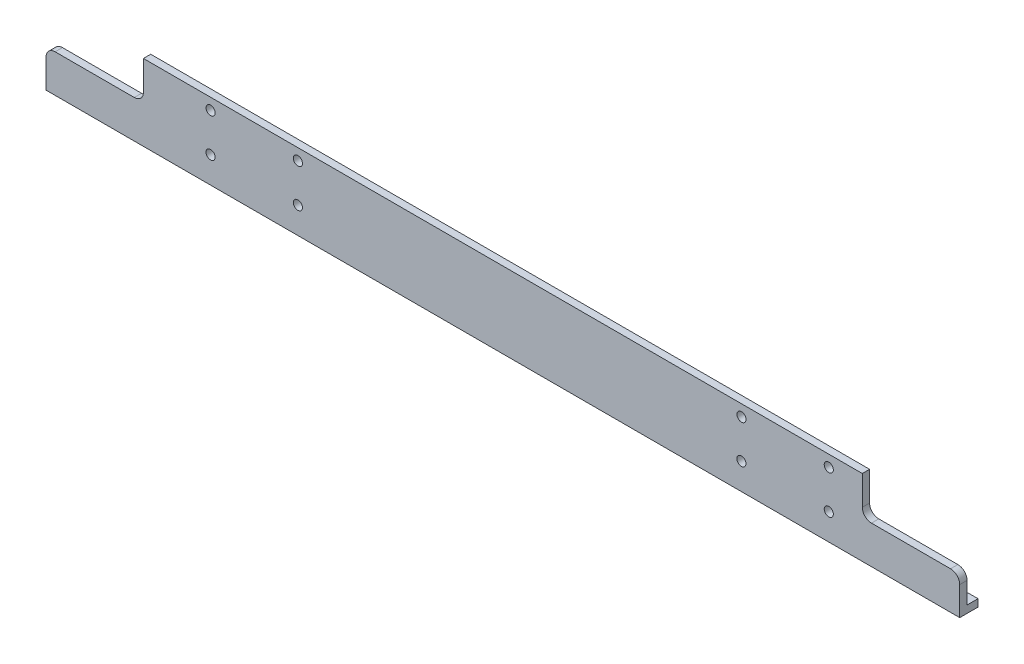
from build123d import *

# Parameters (mm, degrees)
BOSS_EXTRUDE1_DEPTH     = 190.5
F_6_CLEARANCE_HOLE1_D   = 3.7973
CUT_EXTRUDE1_DEPTH      = 196.720144594
CUT_EXTRUDE2_DEPTH      = 196.720144594
CUT_EXTRUDE2_DEPTH_BACK = 196.720144594
SKETCH6_W               = 25.4
SKETCH6_H               = 15.24


with BuildPart() as part:
    # Sketch1 → Boss-Extrude1 (new, symmetric)
    with BuildSketch(Plane(origin=(0, 0, 0), x_dir=(0, 0, -1), z_dir=(1, 0, 0))):
        Polygon((0, 0), (31.75, 0), (31.75, 3.048), (3.048, 3.048), (3.048, 31.75), (0, 31.75), align=None)
    extrude(amount=BOSS_EXTRUDE1_DEPTH, both=True)

    # 6 Clearance Hole1 (through all)
    with Locations(Plane.XY):
        with Locations((135.9, 27), (135.9, 11), (99.5, 27), (99.468, 11), (-121.868, 27), (-121.868, 11), (-85.468, 11), (-85.468, 27)):
            Hole(F_6_CLEARANCE_HOLE1_D / 2)

    # Sketch5 → Cut-Extrude1 (cut, through all)
    with BuildSketch(Plane.XY):
        with BuildLine():
            Line((149.877, 41.148), (149.877, 19.558))
            ThreePointArc((149.877, 19.558), (150.992923164, 16.863923164), (153.687, 15.748))
            Line((153.687, 15.748), (186.69, 15.748))
            ThreePointArc((186.69, 15.748), (189.384076836, 14.632076836), (190.5, 11.938))
            Line((190.5, 11.938), (190.5, -9.652))
            Line((190.5, -9.652), (198.12, -9.652))
            Line((198.12, -9.652), (198.12, 41.148))
            Line((198.12, 41.148), (149.877, 41.148))
        make_face()
        with BuildLine():
            Line((-198.12, 41.148), (-149.877, 41.148))
            Line((-149.877, 41.148), (-149.877, 19.558))
            ThreePointArc((-149.877, 19.558), (-150.992923164, 16.863923164), (-153.687, 15.748))
            Line((-153.687, 15.748), (-186.69, 15.748))
            ThreePointArc((-186.69, 15.748), (-189.384076836, 14.632076836), (-190.5, 11.938))
            Line((-190.5, 11.938), (-190.5, -9.652))
            Line((-190.5, -9.652), (-198.12, -9.652))
            Line((-198.12, -9.652), (-198.12, 41.148))
        make_face()
    extrude(amount=-CUT_EXTRUDE1_DEPTH, mode=Mode.SUBTRACT)

    # Sketch6 → Cut-Extrude2 (cut, two sides: drawn at the far end of the back side and taken through both)
    with BuildSketch(Plane(origin=(0, 0, 0), x_dir=(0, 0, -1), z_dir=(1, 0, 0)).offset(-CUT_EXTRUDE2_DEPTH_BACK)):
        with Locations((20.32, 0)):
            Rectangle(SKETCH6_W, SKETCH6_H)
    extrude(amount=CUT_EXTRUDE2_DEPTH + CUT_EXTRUDE2_DEPTH_BACK, mode=Mode.SUBTRACT)


solid = part.part
